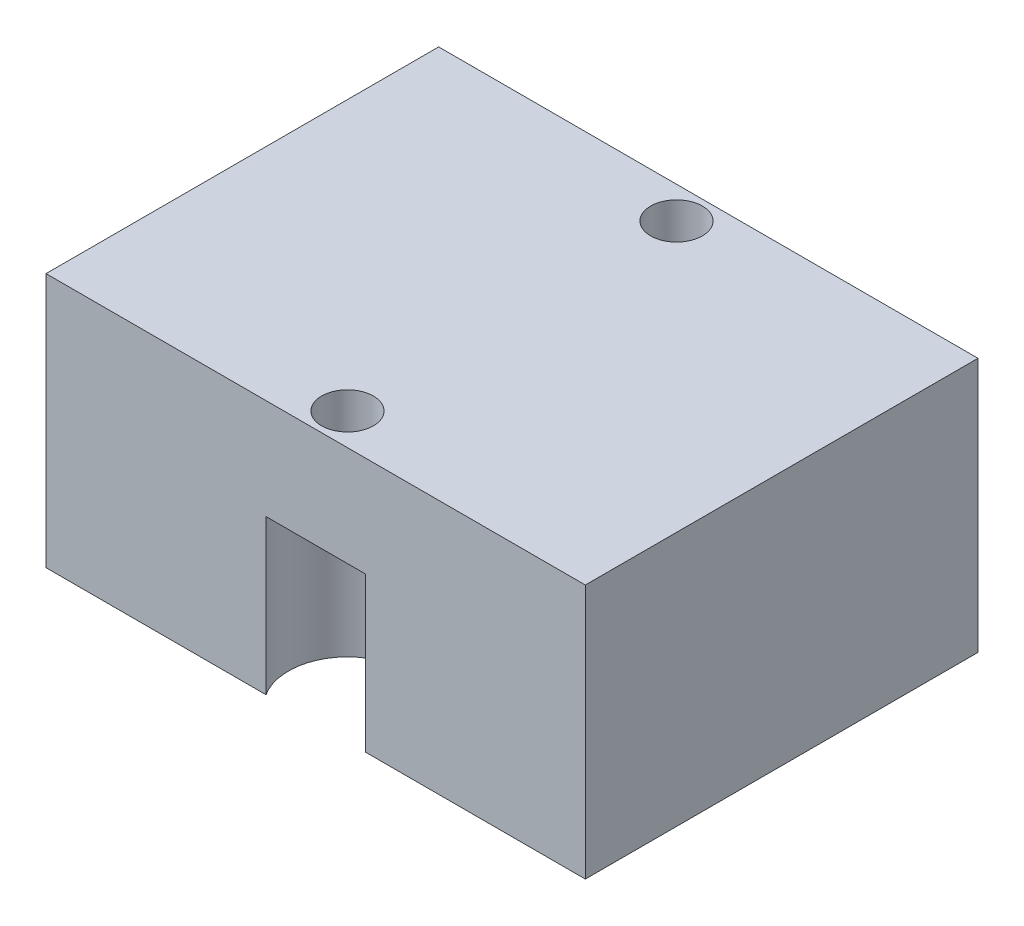
from build123d import *

# Parameters (mm, degrees)
SKETCH1_W                                           = 25.41
SKETCH1_H                                           = 18.5
BOSS_EXTRUDE1_DEPTH                                 = 12
F_2_56_TAPPED_HOLE1_D                               = 1.778
F_2_56_TAPPED_HOLE1_DEPTH                           = 7.46583491
F_2_56_TAPPED_HOLE1_TIP                             = 0.53416509
SKETCH5_R                                           = 3
CUT_EXTRUDE1_DEPTH                                  = 3
CBORE_FOR_2_BINDING_HEAD_MACHINE_SCREW3_D           = 2.4384
CBORE_FOR_2_BINDING_HEAD_MACHINE_SCREW3_CBORE_D     = 5.55752
CBORE_FOR_2_BINDING_HEAD_MACHINE_SCREW3_CBORE_DEPTH = 7.269988


with BuildPart() as part:
    # Sketch1 → Boss-Extrude1 (new body)
    with BuildSketch(Plane(origin=(0, 0, 0), x_dir=(1, 0, 0), z_dir=(0, 1, 0))):
        with Locations((12.705, 9.25)):
            Rectangle(SKETCH1_W, SKETCH1_H)
    extrude(amount=BOSS_EXTRUDE1_DEPTH)

    # #2-56 Tapped Hole1
    with Locations(Plane(origin=(0, 0, 0), x_dir=(-1, 0, 0), z_dir=(0, -1, 0))):
        with Locations((-23.91, 17), (-23.91, 1.5), (-1.5, 1.5), (-1.5, 17)):
            Hole(F_2_56_TAPPED_HOLE1_D / 2, depth=F_2_56_TAPPED_HOLE1_DEPTH)
            with Locations((0, 0, -(F_2_56_TAPPED_HOLE1_DEPTH + F_2_56_TAPPED_HOLE1_TIP / 2))):  # 118° drill point
                Cone(0, F_2_56_TAPPED_HOLE1_D / 2, F_2_56_TAPPED_HOLE1_TIP, mode=Mode.SUBTRACT)

    # Sketch5 → Cut-Extrude1 (cut)
    with BuildSketch(Plane.XZ):
        with Locations((12.705, -9.25)):
            Circle(SKETCH5_R)
    extrude(amount=-CUT_EXTRUDE1_DEPTH, mode=Mode.SUBTRACT)

    # CBORE for #2 Binding Head Machine Screw3 (through all)
    with Locations(Plane(origin=(0, 0, 0), x_dir=(-1, 0, 0), z_dir=(0, -1, 0))):
        with Locations((-12.705, 17), (-12.705, 1.5)):
            CounterBoreHole(CBORE_FOR_2_BINDING_HEAD_MACHINE_SCREW3_D / 2, CBORE_FOR_2_BINDING_HEAD_MACHINE_SCREW3_CBORE_D / 2, CBORE_FOR_2_BINDING_HEAD_MACHINE_SCREW3_CBORE_DEPTH)


solid = part.part
